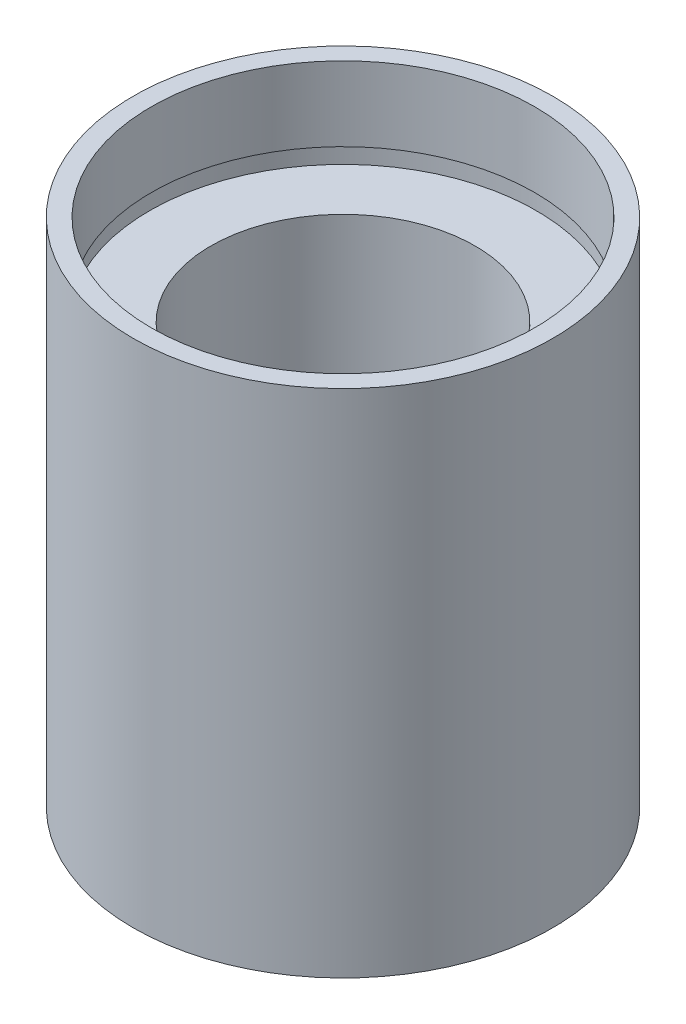
from build123d import *


with BuildPart() as part:
    # 草图1 → 旋转1 (revolve)
    with BuildSketch(Plane.XY, mode=Mode.PRIVATE) as revolve_1_sk:
        Polygon((11.1, 0), (11.1, 4.5), (11.7, 4.5), (11.7, 5.5), (8, 5.5), (8, 25.4), (11.7, 25.4), (11.7, 26.4), (11.6, 26.4), (11.6, 30.9), (12.7, 30.9), (12.7, 0), align=None)
    revolve(revolve_1_sk.sketch.rotate(Axis((0, 161.376166943, 0), (0, -1, 0)), 90), axis=Axis((0, 161.376166943, 0), (0, -1, 0)))  # turned: the seam where the file's is


solid = part.part
